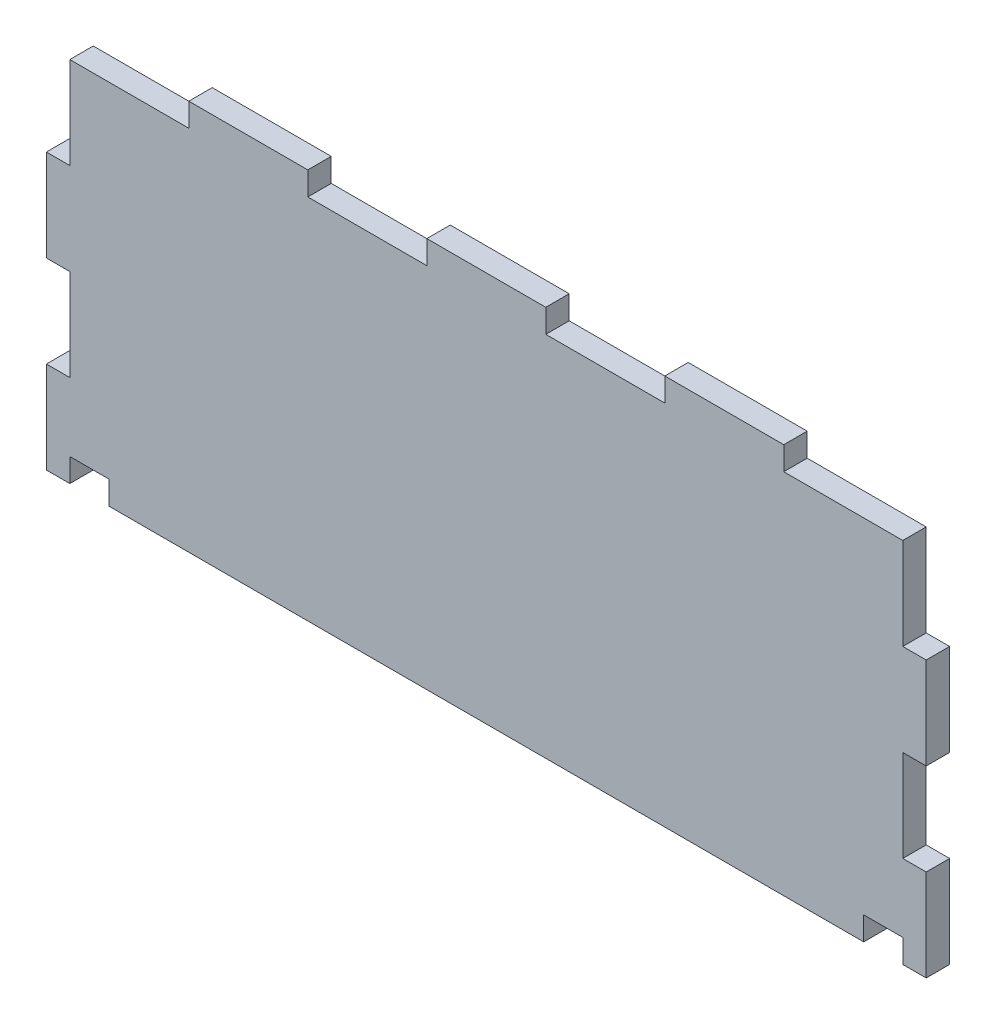
from build123d import *

# Parameters (mm, degrees)
SALIENTE_EXTRUIR1_DEPTH = 3


with BuildPart() as part:
    # Croquis1 → Saliente-Extruir1 (new body)
    with BuildSketch(Plane.XY):
        Polygon((-76.15, 3.886135347), (-76.15, 15.636135347), (-60.92, 15.636135347), (-60.92, 18.636135347), (-45.69, 18.636135347), (-45.69, 15.636135347), (-30.46, 15.636135347), (-30.46, 18.636135347), (-15.23, 18.636135347), (-15.23, 15.636135347), (0, 15.636135347), (0, 18.636135347), (15.23, 18.636135347), (15.23, 15.636135347), (30.46, 15.636135347), (30.46, 3.886135347), (33.46, 3.886135347), (33.46, -7.863864653), (30.46, -7.863864653), (30.46, -19.613864653), (33.46, -19.613864653), (33.46, -31.363864653), (30.46, -31.363864653), (30.46, -28.363864653), (25.46, -28.363864653), (25.46, -31.363864653), (-71.15, -31.363864653), (-71.15, -28.363864653), (-76.15, -28.363864653), (-76.15, -31.363864653), (-79.15, -31.363864653), (-79.15, -19.613864653), (-76.15, -19.613864653), (-76.15, -7.863864653), (-79.15, -7.863864653), (-79.15, 3.886135347), align=None)
    extrude(amount=SALIENTE_EXTRUIR1_DEPTH)


solid = part.part
